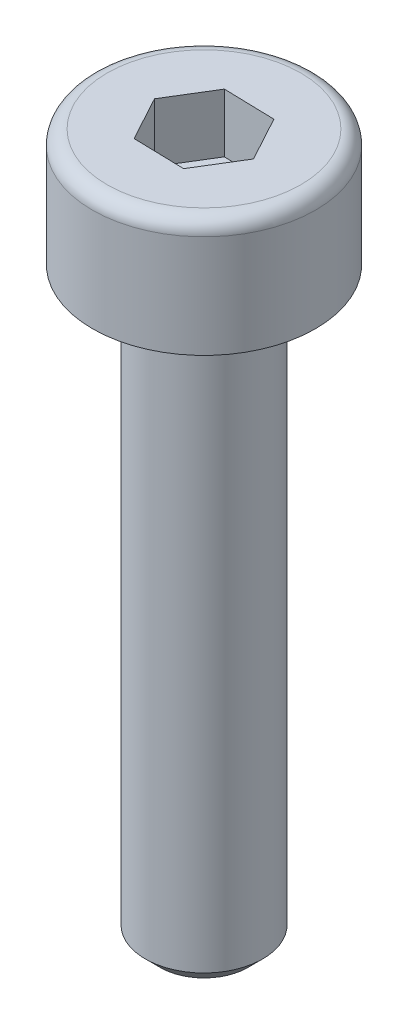
from build123d import *

# Parameters (mm, degrees)
DIAMETRE_TETE_R     = 1.9
HAUTEUR_TETE_DEPTH  = 2
CONGE_R             = 0.25
DIAMETRE_R          = 1
LONGUEUR_DEPTH      = 10
HAUTEUR_6PANS_DEPTH = 1
CHANFREIN_SIZE      = 0.25


with BuildPart() as part:
    # DIAMETRE_TETE → HAUTEUR_TETE (new body)
    with BuildSketch(Plane(origin=(0, 0, 0), x_dir=(1, 0, 0), z_dir=(0, 1, 0))):
        with Locations(Location((0, 0, 0), (0, 0, 270))):  # turned: the seam where the file's is
            Circle(DIAMETRE_TETE_R)
    extrude(amount=HAUTEUR_TETE_DEPTH)

    # CONGE
    conge_edges = [part.edges().sort_by_distance(p)[0] for p in [
        (0, 2, -1.9),
    ]]
    fillet(conge_edges, radius=CONGE_R)

    # DIAMETRE → LONGUEUR (add)
    with BuildSketch(Plane.XZ):
        with Locations(Location((0, 0, 0), (0, 0, 270))):  # turned: the seam where the file's is
            Circle(DIAMETRE_R)
    extrude(amount=LONGUEUR_DEPTH)

    # LARGEUR_6PANS → HAUTEUR_6PANS (cut)
    with BuildSketch(Plane(origin=(0, 2, 0), x_dir=(1, 0, 0), z_dir=(0, 1, 0))):
        Polygon((0.452370674, 0.738485459), (-0.413361831, 0.761007225), (-0.865732505, 0.022521766), (-0.452370674, -0.738485459), (0.413361831, -0.761007225), (0.865732505, -0.022521766), align=None)
    extrude(amount=-HAUTEUR_6PANS_DEPTH, mode=Mode.SUBTRACT)

    # CHANFREIN
    chanfrein_edges = [part.edges().sort_by_distance(p)[0] for p in [
        (0, -10, 1),
    ]]
    chamfer(chanfrein_edges, length=CHANFREIN_SIZE)


solid = part.part
